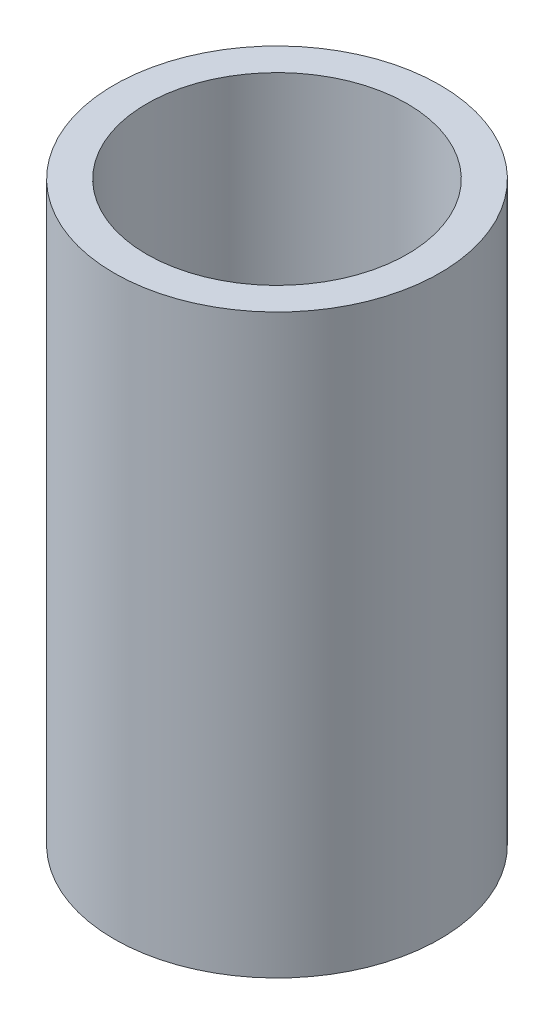
from build123d import *

# Parameters (mm, degrees)
SKETCH1_R           = 5
SKETCH1_R_2         = 4
BOSS_EXTRUDE1_DEPTH = 17.7


with BuildPart() as part:
    # Sketch1 → Boss-Extrude1 (new body)
    with BuildSketch(Plane(origin=(0, 0, 0), x_dir=(1, 0, 0), z_dir=(0, 1, 0))):
        Circle(SKETCH1_R)
        Circle(SKETCH1_R_2, mode=Mode.SUBTRACT)
    extrude(amount=BOSS_EXTRUDE1_DEPTH)


solid = part.part
